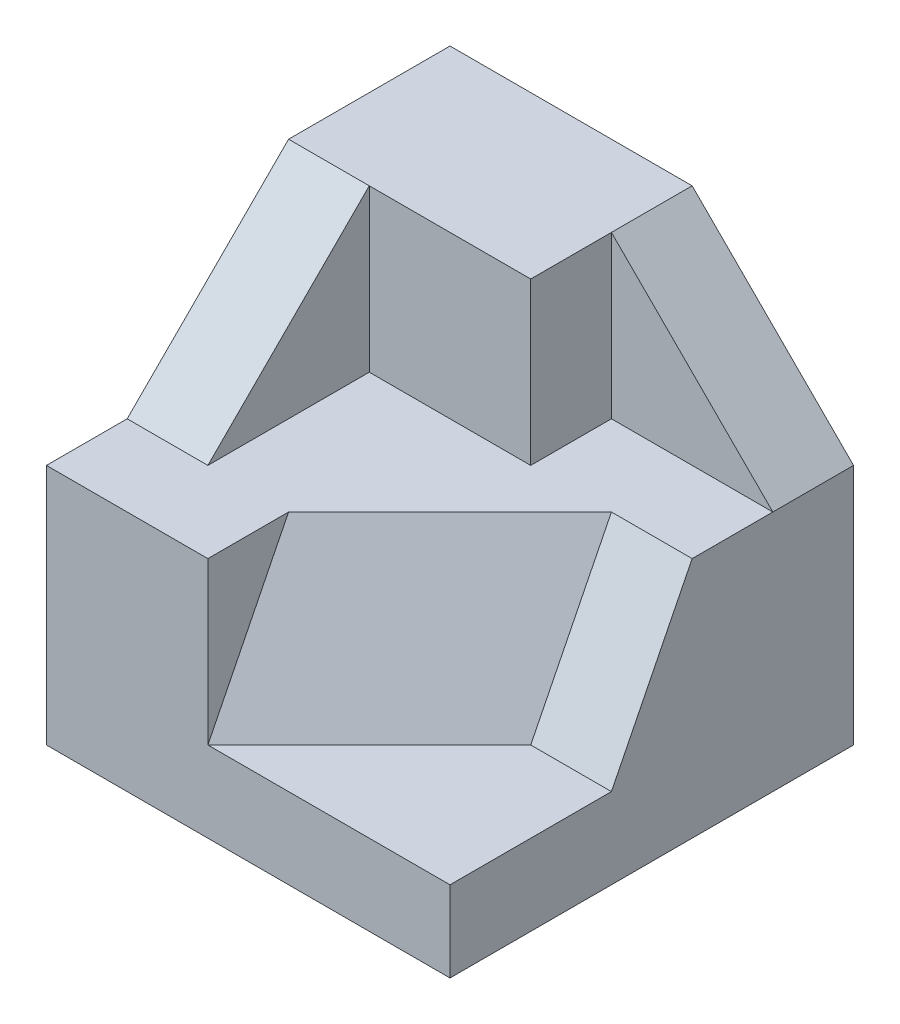
from build123d import *

# Parameters (mm, degrees)
SKETCH1_W           = 5
SKETCH1_H           = 5
BOSS_EXTRUDE1_DEPTH = 5
CUT_EXTRUDE1_DEPTH  = 2
CUT_EXTRUDE2_DEPTH  = 1
SKETCH4_W           = 3
SKETCH4_H           = 2
CUT_EXTRUDE3_DEPTH  = 3
SKETCH5_W           = 2
SKETCH5_H           = 2
CUT_EXTRUDE4_DEPTH  = 1
CUT_EXTRUDE5_DEPTH  = 1
CUT_EXTRUDE6_DEPTH  = 2
CUT_EXTRUDE7_DEPTH  = 1
CUT_EXTRUDE8_DEPTH  = 3
CUT_EXTRUDE9_DEPTH  = 3


with BuildPart() as part:
    # Sketch1 → Boss-Extrude1 (new body)
    with BuildSketch(Plane.XY):
        Rectangle(SKETCH1_W, SKETCH1_H)
    extrude(amount=BOSS_EXTRUDE1_DEPTH)

    # Sketch2 → Cut-Extrude1 (cut)
    with BuildSketch(Plane(origin=(0, 2.5, 0), x_dir=(1, 0, 0), z_dir=(0, 1, 0))):
        Polygon((-2.5, -5), (-0.5, -5), (-0.5, -2), (-1.5, -2), (-1.5, -4), (-2.5, -4), align=None)
    extrude(amount=-CUT_EXTRUDE1_DEPTH, mode=Mode.SUBTRACT)

    # Sketch3 → Cut-Extrude2 (cut)
    with BuildSketch(Plane.ZY.offset(2.5)):
        Polygon((4, 0.5), (2, 2.5), (4, 2.5), align=None)
    extrude(amount=-CUT_EXTRUDE2_DEPTH, mode=Mode.SUBTRACT)

    # Sketch4 → Cut-Extrude3 (cut)
    with BuildSketch(Plane.XY.offset(5)):
        with Locations((1, 1.5)):
            Rectangle(SKETCH4_W, SKETCH4_H)
    extrude(amount=-CUT_EXTRUDE3_DEPTH, mode=Mode.SUBTRACT)

    # Sketch5 → Cut-Extrude4 (cut)
    with BuildSketch(Plane.XY.offset(2)):
        with Locations((1.5, 1.5)):
            Rectangle(SKETCH5_W, SKETCH5_H)
    extrude(amount=-CUT_EXTRUDE4_DEPTH, mode=Mode.SUBTRACT)

    # Sketch6 → Cut-Extrude5 (cut)
    with BuildSketch(Plane.XY.offset(1)):
        Polygon((2.5, 0.5), (0.5, 2.5), (2.5, 2.5), align=None)
    extrude(amount=-CUT_EXTRUDE5_DEPTH, mode=Mode.SUBTRACT)

    # Sketch7 → Cut-Extrude6 (cut)
    with BuildSketch(Plane(origin=(0, 0.5, 0), x_dir=(1, 0, 0), z_dir=(0, 1, 0))):
        Polygon((2.5, -5), (2.5, -3), (1.5, -3), (-0.5, -5), align=None)
    extrude(amount=-CUT_EXTRUDE6_DEPTH, mode=Mode.SUBTRACT)

    # Sketch8 → Cut-Extrude7 (cut)
    with BuildSketch(Plane(origin=(2.5, 0, 0), x_dir=(0, 0, -1), z_dir=(1, 0, 0))):
        Polygon((-3, -1.5), (-2, 0.5), (-3, 0.5), align=None)
    extrude(amount=-CUT_EXTRUDE7_DEPTH, mode=Mode.SUBTRACT)

    # Sketch9 → Cut-Extrude8 (cut)
    with BuildSketch(Plane(origin=(2.5, 0, 0), x_dir=(0, 0, -1), z_dir=(1, 0, 0))):
        Polygon((-5, -1.5), (-4, 0.5), (-5, 0.5), align=None)
    extrude(amount=-CUT_EXTRUDE8_DEPTH, mode=Mode.SUBTRACT)

    # Sketch11 → Cut-Extrude9 (cut)
    with BuildSketch(Plane(origin=(1.666666667, 0.833333333, 1.666666667), x_dir=(-0.745355992, 0.298142397, 0.596284794), z_dir=(-0.666666667, -0.333333333, -0.666666667))):
        Polygon((2.906888371, -1.341640786), (0.223606798, -0.447213595), (0.223606798, -2.683281573), (2.906888371, -3.577708764), align=None)
    extrude(amount=-CUT_EXTRUDE9_DEPTH, mode=Mode.SUBTRACT)


solid = part.part
